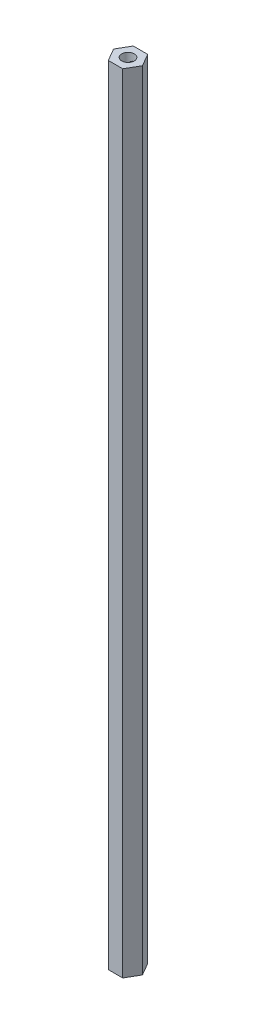
from build123d import *

# Parameters (mm, degrees)
BOSS_EXTRUDE1_DEPTH             = 200
F_1_4_0_25_DIAMETER_HOLE1_D     = 6.35
F_1_4_0_25_DIAMETER_HOLE1_DEPTH = 20
F_1_4_0_25_DIAMETER_HOLE1_TIP   = 1.907732465
F_1_4_0_25_DIAMETER_HOLE2_D     = 6.35
F_1_4_0_25_DIAMETER_HOLE2_DEPTH = 20
F_1_4_0_25_DIAMETER_HOLE2_TIP   = 1.907732465
M6X1_0_TAPPED_HOLE3_REACH       = 202.537
M6X1_0_TAPPED_HOLE3_BORE_R      = 2.5
M6X1_0_TAPPED_HOLE4_REACH       = 202.637
M6X1_0_TAPPED_HOLE4_BORE_R      = 2.5


with BuildPart() as part:
    # Sketch1 → Boss-Extrude1 (new, symmetric)
    with BuildSketch(Plane(origin=(0, 0, 0), x_dir=(1, 0, 0), z_dir=(0, 1, 0))):
        Polygon((7.332348419, 0), (3.666174209, 6.35), (-3.666174209, 6.35), (-7.332348419, 0), (-3.666174209, -6.35), (3.666174209, -6.35), align=None)
    extrude(amount=BOSS_EXTRUDE1_DEPTH, both=True)

    # 1_4 _0.25_ Diameter Hole1
    with Locations(Plane(origin=(0, 200, 0), x_dir=(1, 0, 0), z_dir=(0, 1, 0))):
        with Locations((0, 0)):
            Hole(F_1_4_0_25_DIAMETER_HOLE1_D / 2, depth=F_1_4_0_25_DIAMETER_HOLE1_DEPTH)
            with Locations((0, 0, -(F_1_4_0_25_DIAMETER_HOLE1_DEPTH + F_1_4_0_25_DIAMETER_HOLE1_TIP / 2))):  # 118° drill point
                Cone(0, F_1_4_0_25_DIAMETER_HOLE1_D / 2, F_1_4_0_25_DIAMETER_HOLE1_TIP, mode=Mode.SUBTRACT)

    # 1_4 _0.25_ Diameter Hole2
    with Locations(Plane(origin=(0, -200, 0), x_dir=(-1, 0, 0), z_dir=(0, -1, 0))):
        with Locations((0, 0)):
            Hole(F_1_4_0_25_DIAMETER_HOLE2_D / 2, depth=F_1_4_0_25_DIAMETER_HOLE2_DEPTH)
            with Locations((0, 0, -(F_1_4_0_25_DIAMETER_HOLE2_DEPTH + F_1_4_0_25_DIAMETER_HOLE2_TIP / 2))):  # 118° drill point
                Cone(0, F_1_4_0_25_DIAMETER_HOLE2_D / 2, F_1_4_0_25_DIAMETER_HOLE2_TIP, mode=Mode.SUBTRACT)

    # M6x1.0 Tapped Hole3 bore → M6x1.0 Tapped Hole3 (cut, up to next)
    with BuildSketch(Plane(origin=(0, 0, -6.35), x_dir=(-1, 0, 0), z_dir=(0, 0, -1)), mode=Mode.PRIVATE) as m6x1_0_tapped_hole3_sk1:
        with Locations((0, -194)):
            Circle(M6X1_0_TAPPED_HOLE3_BORE_R)
    m6x1_0_tapped_hole3_tool1 = extrude(m6x1_0_tapped_hole3_sk1.sketch, amount=-M6X1_0_TAPPED_HOLE3_REACH, mode=Mode.PRIVATE) & part.part
    # M6x1.0 Tapped Hole3 bore → M6x1.0 Tapped Hole3 (cut, up to next)
    with BuildSketch(Plane(origin=(0, 0, -6.35), x_dir=(-1, 0, 0), z_dir=(0, 0, -1)), mode=Mode.PRIVATE) as m6x1_0_tapped_hole3_sk2:
        with Locations((0, 194)):
            Circle(M6X1_0_TAPPED_HOLE3_BORE_R)
    m6x1_0_tapped_hole3_tool2 = extrude(m6x1_0_tapped_hole3_sk2.sketch, amount=-M6X1_0_TAPPED_HOLE3_REACH, mode=Mode.PRIVATE) & part.part
    add(m6x1_0_tapped_hole3_tool1.solids().sort_by_distance((0, -194, -6.35))[0], mode=Mode.SUBTRACT)
    add(m6x1_0_tapped_hole3_tool2.solids().sort_by_distance((0, 194, -6.35))[0], mode=Mode.SUBTRACT)

    # M6x1.0 Tapped Hole4 bore → M6x1.0 Tapped Hole4 (cut, up to next)
    with BuildSketch(Plane(origin=(-5.499261314, 0, 3.175), x_dir=(-0.5000000000000001, 0, -0.8660254037844386), z_dir=(-0.8660254037844386, 0, 0.5000000000000001)), mode=Mode.PRIVATE) as m6x1_0_tapped_hole4_sk1:
        with Locations((0, -194)):
            Circle(M6X1_0_TAPPED_HOLE4_BORE_R)
    m6x1_0_tapped_hole4_tool1 = extrude(m6x1_0_tapped_hole4_sk1.sketch, amount=-M6X1_0_TAPPED_HOLE4_REACH, mode=Mode.PRIVATE) & part.part
    # M6x1.0 Tapped Hole4 bore → M6x1.0 Tapped Hole4 (cut, up to next)
    with BuildSketch(Plane(origin=(-5.499261314, 0, 3.175), x_dir=(-0.5000000000000001, 0, -0.8660254037844386), z_dir=(-0.8660254037844386, 0, 0.5000000000000001)), mode=Mode.PRIVATE) as m6x1_0_tapped_hole4_sk2:
        with Locations((0, 194)):
            Circle(M6X1_0_TAPPED_HOLE4_BORE_R)
    m6x1_0_tapped_hole4_tool2 = extrude(m6x1_0_tapped_hole4_sk2.sketch, amount=-M6X1_0_TAPPED_HOLE4_REACH, mode=Mode.PRIVATE) & part.part
    add(m6x1_0_tapped_hole4_tool1.solids().sort_by_distance((-5.499261, 194, 3.175))[0], mode=Mode.SUBTRACT)
    add(m6x1_0_tapped_hole4_tool2.solids().sort_by_distance((-5.499261, -194, 3.175))[0], mode=Mode.SUBTRACT)


solid = part.part
